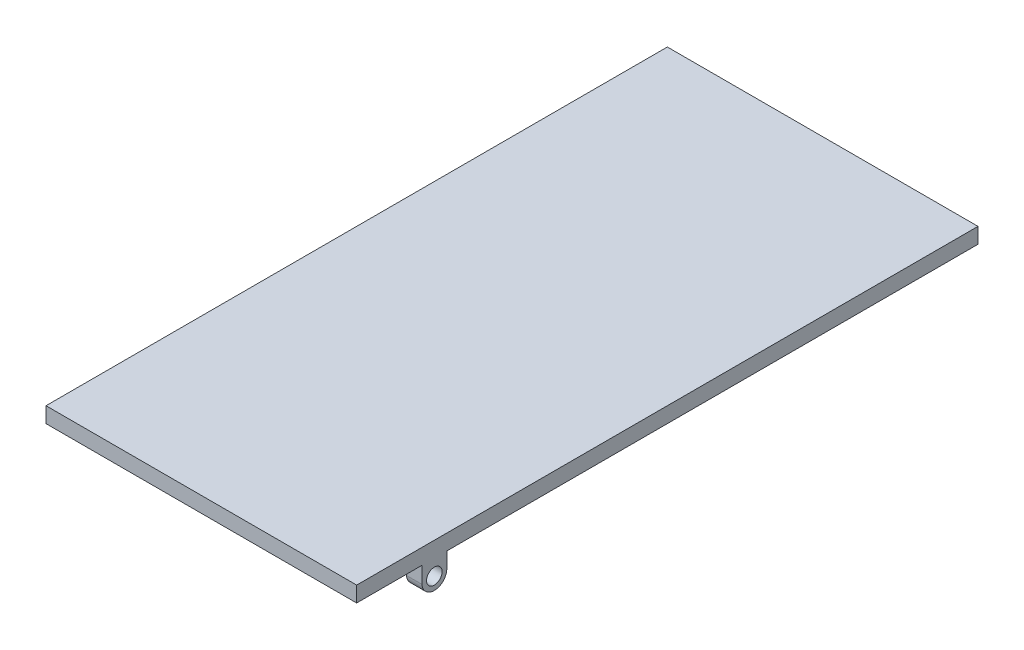
from build123d import *

# Parameters (mm, degrees)
SKETCH3_W           = 200
SKETCH3_H           = 10
BOSS_EXTRUDE1_DEPTH = 400
SKETCH4_R           = 5
BOSS_EXTRUDE2_DEPTH = 200
SKETCH5_W           = 180
SKETCH5_H           = 16
CUT_EXTRUDE1_DEPTH  = 75


with BuildPart() as part:
    # Sketch3 → Boss-Extrude1 (new body)
    with BuildSketch(Plane.XY):
        with Locations((100, 5)):
            Rectangle(SKETCH3_W, SKETCH3_H)
    extrude(amount=BOSS_EXTRUDE1_DEPTH)

    # Sketch4 → Boss-Extrude2 (add)
    with BuildSketch(Plane(origin=(200, 0, 0), x_dir=(0, 0, -1), z_dir=(1, 0, 0))):
        with BuildLine():
            Line((-342, 0), (-358, 0))
            Line((-358, 0), (-358, -9.403084831))
            Line((-358, -9.403084831), (-358, -10.596915169))
            ThreePointArc((-358, -10.596915169), (-350, -18.022238323), (-342, -10.596915169))
            Line((-342, -10.596915169), (-342, -9.403084831))
            Line((-342, -9.403084831), (-342, 0))
        make_face()
        with Locations((-350, -10)):
            Circle(SKETCH4_R, mode=Mode.SUBTRACT)
    extrude(amount=-BOSS_EXTRUDE2_DEPTH)

    # Sketch5 → Cut-Extrude1 (cut)
    with BuildSketch(Plane.XZ):
        with Locations((100, 350)):
            Rectangle(SKETCH5_W, SKETCH5_H)
    extrude(amount=CUT_EXTRUDE1_DEPTH, mode=Mode.SUBTRACT)


solid = part.part
